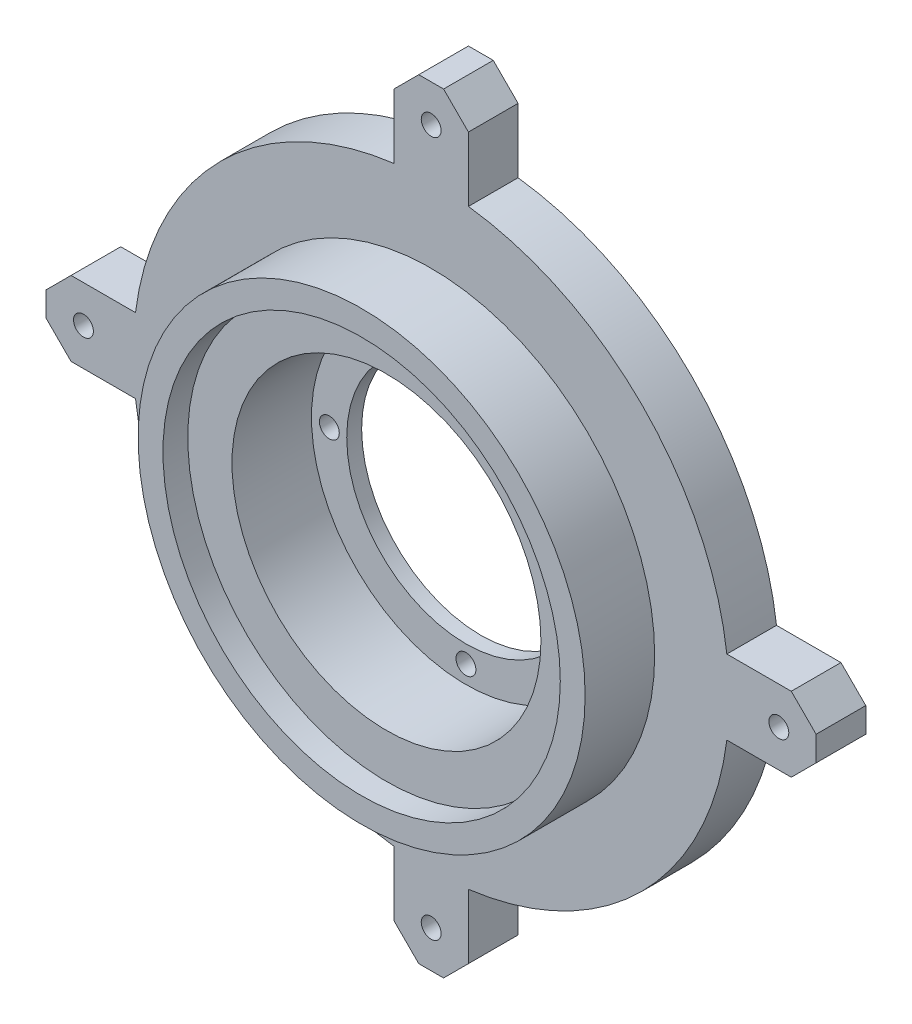
from build123d import *

# Parameters (mm, degrees)
BOSS_EXTRUDE1_DEPTH             = 10
SKETCH2_R                       = 45
BOSS_EXTRUDE2_DEPTH             = 14
SKETCH3_R                       = 31.1
CUT_EXTRUDE1_DEPTH              = 21
F_4_0MM_DOWEL_HOLE1_D           = 4
F_4_0MM_DOWEL_HOLE1_CSINK_D     = 4.05
F_4_0MM_DOWEL_HOLE1_CSINK_ANGLE = 90
SKETCH11_R                      = 40
CUT_EXTRUDE2_DEPTH              = 5
SKETCH4_R                       = 24
CUT_EXTRUDE3_DEPTH              = 4
SKETCH12_R                      = 2
CUT_EXTRUDE5_DEPTH              = 4


with BuildPart() as part:
    # Sketch1 → Boss-Extrude1 (new body)
    with BuildSketch(Plane.XY):
        with BuildLine():
            Line((-42.5, 7.5), (-59.529404499, 7.5))
            ThreePointArc((-59.529404499, 7.5), (-60, 0), (-59.529404499, -7.5))
            Line((-59.529404499, -7.5), (-42.5, -7.5))
            Line((-42.5, -7.5), (-42.5, 7.5))
        make_face()
        with BuildLine():
            ThreePointArc((-7.5, 59.529404499), (-42.426406871, 42.426406871), (-59.529404499, 7.5))
            Line((-59.529404499, 7.5), (-42.5, 7.5))
            Line((-42.5, 7.5), (-42.5, -7.5))
            Line((-42.5, -7.5), (-59.529404499, -7.5))
            ThreePointArc((-59.529404499, -7.5), (-42.426406871, -42.426406871), (-7.5, -59.529404499))
            Line((-7.5, -59.529404499), (-7.5, -42.5))
            Line((-7.5, -42.5), (7.5, -42.5))
            Line((7.5, -42.5), (7.5, -59.529404499))
            ThreePointArc((7.5, -59.529404499), (42.426406871, -42.426406871), (59.529404499, -7.5))
            Line((59.529404499, -7.5), (42.5, -7.5))
            Line((42.5, -7.5), (42.5, 7.5))
            Line((42.5, 7.5), (59.529404499, 7.5))
            ThreePointArc((59.529404499, 7.5), (42.426406871, 42.426406871), (7.5, 59.529404499))
            Line((7.5, 59.529404499), (7.5, 42.5))
            Line((7.5, 42.5), (-7.5, 42.5))
            Line((-7.5, 42.5), (-7.5, 59.529404499))
        make_face()
        with BuildLine():
            ThreePointArc((7.5, 59.529404499), (0, 60), (-7.5, 59.529404499))
            Line((-7.5, 59.529404499), (-7.5, 42.5))
            Line((-7.5, 42.5), (7.5, 42.5))
            Line((7.5, 42.5), (7.5, 59.529404499))
        make_face()
        with BuildLine():
            Line((-7.5, 72.5), (-7.5, 59.529404499))
            ThreePointArc((-7.5, 59.529404499), (0, 60), (7.5, 59.529404499))
            Line((7.5, 59.529404499), (7.5, 72.5))
            Line((7.5, 72.5), (2.5, 77.5))
            Line((2.5, 77.5), (-2.5, 77.5))
            Line((-2.5, 77.5), (-7.5, 72.5))
        make_face()
        with BuildLine():
            Line((-59.529404499, 7.5), (-72.5, 7.5))
            Line((-72.5, 7.5), (-77.5, 2.5))
            Line((-77.5, 2.5), (-77.5, -2.5))
            Line((-77.5, -2.5), (-72.5, -7.5))
            Line((-72.5, -7.5), (-59.529404499, -7.5))
            ThreePointArc((-59.529404499, -7.5), (-60, 0), (-59.529404499, 7.5))
        make_face()
        with BuildLine():
            ThreePointArc((60, 0), (59.882235554, 3.757374753), (59.529404499, 7.5))
            Line((59.529404499, 7.5), (42.5, 7.5))
            Line((42.5, 7.5), (42.5, -7.5))
            Line((42.5, -7.5), (59.529404499, -7.5))
            ThreePointArc((59.529404499, -7.5), (59.882235554, -3.757374753), (60, 0))
        make_face()
        with BuildLine():
            Line((72.5, 7.5), (59.529404499, 7.5))
            ThreePointArc((59.529404499, 7.5), (59.882235554, 3.757374753), (60, 0))
            ThreePointArc((60, 0), (59.882235554, -3.757374753), (59.529404499, -7.5))
            Line((59.529404499, -7.5), (72.5, -7.5))
            Line((72.5, -7.5), (77.5, -2.5))
            Line((77.5, -2.5), (77.5, 2.5))
            Line((77.5, 2.5), (72.5, 7.5))
        make_face()
        with BuildLine():
            ThreePointArc((7.5, -59.529404499), (0, -60), (-7.5, -59.529404499))
            Line((-7.5, -59.529404499), (-7.5, -72.5))
            Line((-7.5, -72.5), (-2.5, -77.5))
            Line((-2.5, -77.5), (2.5, -77.5))
            Line((2.5, -77.5), (7.5, -72.5))
            Line((7.5, -72.5), (7.5, -59.529404499))
        make_face()
        with BuildLine():
            Line((-7.5, -42.5), (-7.5, -59.529404499))
            ThreePointArc((-7.5, -59.529404499), (0, -60), (7.5, -59.529404499))
            Line((7.5, -59.529404499), (7.5, -42.5))
            Line((7.5, -42.5), (-7.5, -42.5))
        make_face()
    extrude(amount=BOSS_EXTRUDE1_DEPTH)

    # Sketch2 → Boss-Extrude2 (add)
    with BuildSketch(Plane.XY.offset(10)):
        Circle(SKETCH2_R)
    extrude(amount=BOSS_EXTRUDE2_DEPTH)

    # Sketch3 → Cut-Extrude1 (cut)
    with BuildSketch(Plane.XY.offset(24)):
        Circle(SKETCH3_R)
    extrude(amount=-CUT_EXTRUDE1_DEPTH, mode=Mode.SUBTRACT)

    # Ø4.0mm Dowel Hole1 (through all)
    with Locations(Plane(origin=(0, 0, 0), x_dir=(-1, 0, 0), z_dir=(0, 0, -1))):
        with Locations((-70, 0), (0, 70), (70, 0), (0, -70)):
            CounterSinkHole(F_4_0MM_DOWEL_HOLE1_D / 2, F_4_0MM_DOWEL_HOLE1_CSINK_D / 2, counter_sink_angle=F_4_0MM_DOWEL_HOLE1_CSINK_ANGLE)

    # Sketch11 → Cut-Extrude2 (cut)
    with BuildSketch(Plane.XY.offset(24)):
        Circle(SKETCH11_R)
    extrude(amount=-CUT_EXTRUDE2_DEPTH, mode=Mode.SUBTRACT)

    # Sketch4 → Cut-Extrude3 (cut)
    with BuildSketch(Plane(origin=(0, 0, 0), x_dir=(-1, 0, 0), z_dir=(0, 0, -1))):
        Circle(SKETCH4_R)
    extrude(amount=-CUT_EXTRUDE3_DEPTH, mode=Mode.SUBTRACT)

    # Sketch12 → Cut-Extrude5 (cut)
    with BuildSketch(Plane(origin=(0, 0, 0), x_dir=(-1, 0, 0), z_dir=(0, 0, -1))):
        with Locations((27.5, 0)):
            Circle(SKETCH12_R)
        with Locations((0, -27.5)):
            Circle(SKETCH12_R)
        with Locations((-27.5, 0)):
            Circle(SKETCH12_R)
        with Locations((0, 27.5)):
            Circle(SKETCH12_R)
    extrude(amount=-CUT_EXTRUDE5_DEPTH, mode=Mode.SUBTRACT)


solid = part.part
